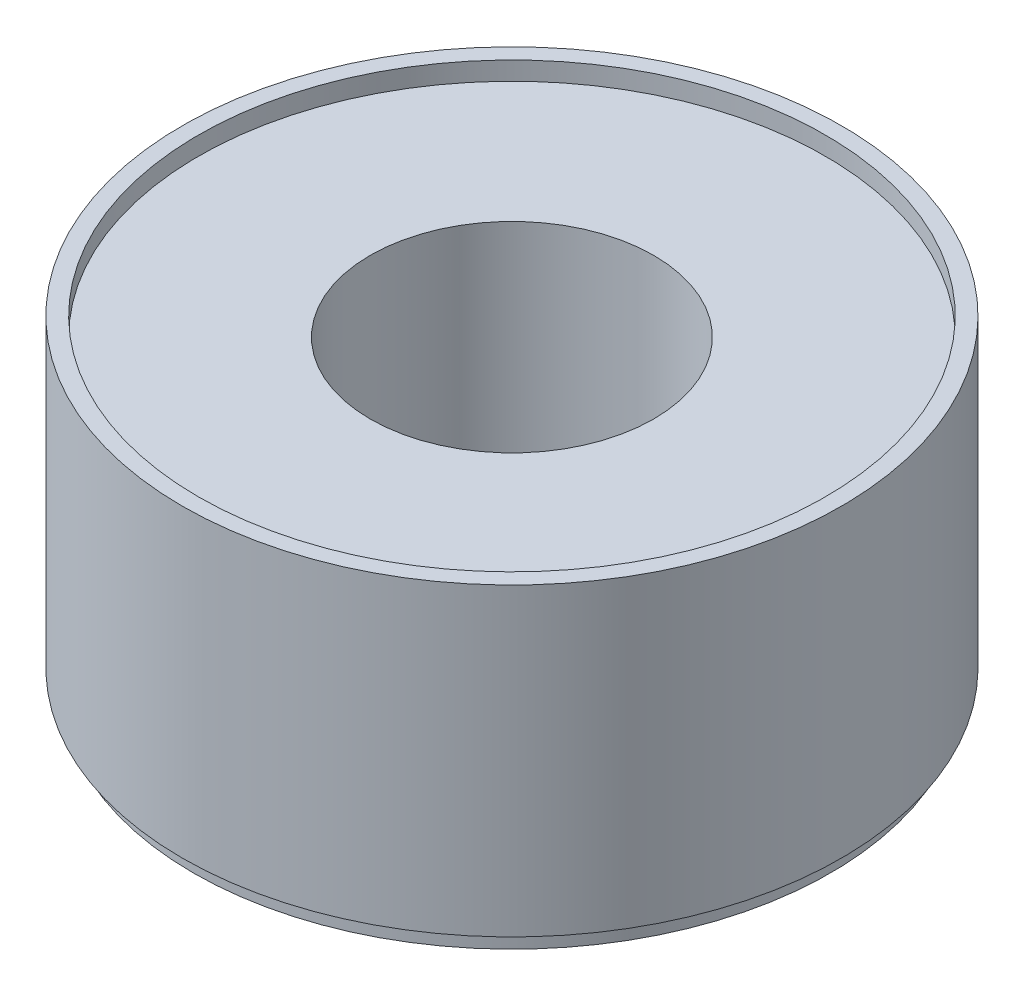
from build123d import *


with BuildPart() as part:
    # Croquis1 → Revolución2 (revolve)
    with BuildSketch(Plane(origin=(0, 0, 0), x_dir=(0, 0, -1), z_dir=(1, 0, 0))):
        Polygon((73.957185569, -85.723101455), (166.163546798, -85.723101455), (166.163546798, -76.11827216), (162.801856545, -76.11827216), (171.926444375, -76.11827216), (171.926444375, 82.888074066), (163.522218742, 82.888074066), (163.522218742, 73.283244772), (148.874854068, 73.283244772), (97.969258806, 73.283244772), (73.957185569, 73.283244772), align=None)
    revolve(axis=Axis((0, 73.236823372, 0), (0, -1, 0)))


solid = part.part
